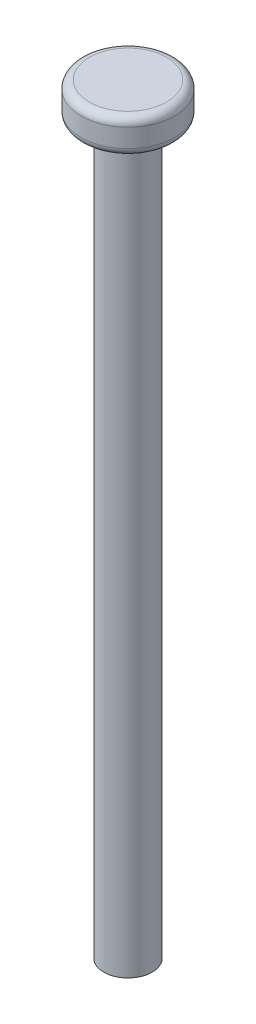
from build123d import *

# Parameters (mm, degrees)
SKETCH1_R           = 3
BOSS_EXTRUDE1_DEPTH = 90
SKETCH2_R           = 5.8
BOSS_EXTRUDE2_DEPTH = 4.3
FILLET1_R           = 1


with BuildPart() as part:
    # Sketch1 → Boss-Extrude1 (new body)
    with BuildSketch(Plane(origin=(0, 0, 0), x_dir=(1, 0, 0), z_dir=(0, 1, 0))):
        with Locations(Location((0, 0, 0), (0, 0, 270))):  # turned: the seam where the file's is
            Circle(SKETCH1_R)
    extrude(amount=BOSS_EXTRUDE1_DEPTH)

    # Sketch2 → Boss-Extrude2 (add)
    with BuildSketch(Plane(origin=(0, 90, 0), x_dir=(1, 0, 0), z_dir=(0, 1, 0))):
        with Locations(Location((0, 0, 0), (0, 0, 270))):  # turned: the seam where the file's is
            Circle(SKETCH2_R)
    extrude(amount=BOSS_EXTRUDE2_DEPTH)

    # Fillet1
    fillet1_edges = [part.edges().sort_by_distance(p)[0] for p in [
        (0, 90, -5.8),
        (0, 94.3, -5.8),
    ]]
    fillet(fillet1_edges, radius=FILLET1_R)


solid = part.part
